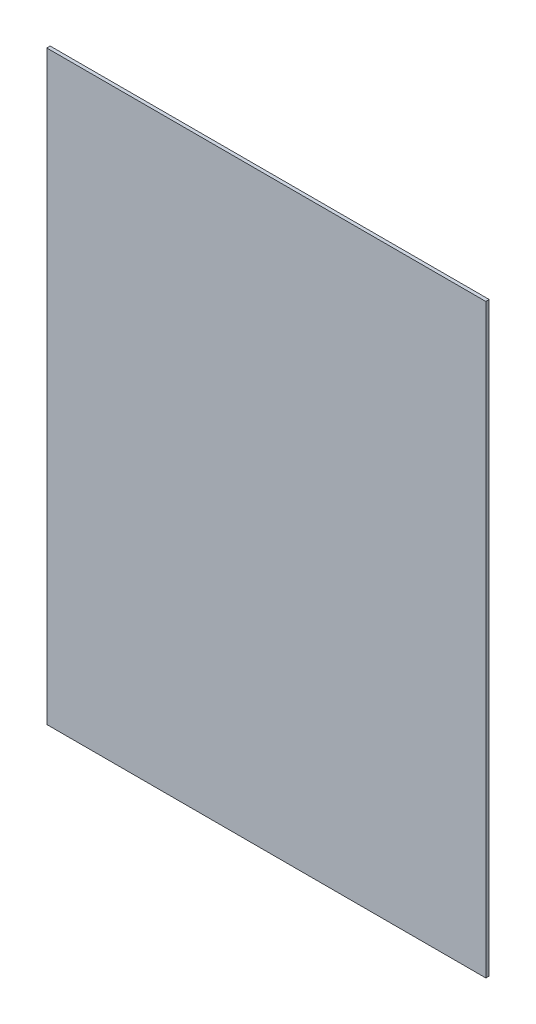
from build123d import *

# Parameters (mm, degrees)
SKETCH1_W  = 154
SKETCH1_H  = 205.5
BODY_DEPTH = 1.190625


with BuildPart() as part:
    # Sketch1 → Body (new body)
    with BuildSketch(Plane.XY):
        Rectangle(SKETCH1_W, SKETCH1_H)
    extrude(amount=BODY_DEPTH)


solid = part.part
